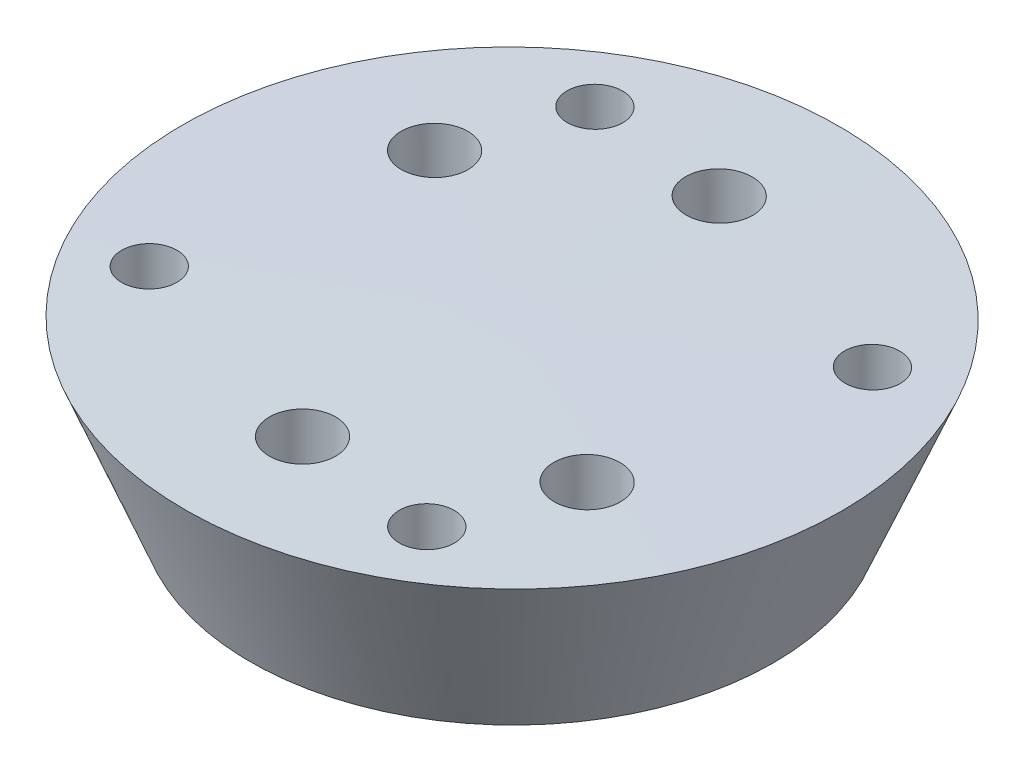
from build123d import *

# Parameters (mm, degrees)
SCHIZZO2_R                    = 2.5
TAGLIO_ESTRUSIONE1_DEPTH      = 21
TAGLIO_ESTRUSIONE1_DEPTH_BACK = 10
TAGLIO_ESTRUSIONE2_DEPTH      = 11
SCHIZZO4_R                    = 4
TAGLIO_ESTRUSIONE3_DEPTH      = 91


with BuildPart() as part:
    # Schizzo1 → Rivoluzione1 (revolve)
    with BuildSketch(Plane.XY):
        Polygon((0, -101.5), (0.147426206, -81.5), (-39.399917748, -81.5), (-31.5, -101.5), align=None)
    revolve(axis=Axis((0, -101.5, 0), (0.00737111, 0.999972833, 0)))

    # Schizzo2 → Taglio-Estrusione1 (cut, two sides)
    with BuildSketch(Plane(origin=(0, -101.5, 0), x_dir=(1, 0, 0), z_dir=(0, 1, 0))) as taglio_estrusione1_sk:
        with Locations((21.650635095, -12.5)):
            Circle(SCHIZZO2_R)
        with Locations((0, -25)):
            Circle(SCHIZZO2_R)
        with Locations((-21.650635095, 12.5)):
            Circle(SCHIZZO2_R)
        with Locations((0, 25)):
            Circle(SCHIZZO2_R)
    extrude(amount=TAGLIO_ESTRUSIONE1_DEPTH, mode=Mode.SUBTRACT)
    extrude(taglio_estrusione1_sk.sketch, amount=-TAGLIO_ESTRUSIONE1_DEPTH_BACK, mode=Mode.SUBTRACT)

    # Schizzo3 → Taglio-Estrusione2 (cut)
    with BuildSketch(Plane.XZ.offset(81.5)):
        with BuildLine():
            ThreePointArc((17.404264159, 23.501763124), (19.888877198, 27.491500276), (15.899140045, 29.976113315))
            ThreePointArc((15.899140045, 29.976113315), (13.414527007, 25.986376162), (17.404264159, 23.501763124))
        make_face()
        with BuildLine():
            ThreePointArc((29.976113315, -15.899140045), (25.986376162, -13.414527007), (23.501763124, -17.404264159))
            ThreePointArc((23.501763124, -17.404264159), (27.491500276, -19.888877198), (29.976113315, -15.899140045))
        make_face()
        with BuildLine():
            ThreePointArc((-15.899140045, -29.976113315), (-13.414527007, -25.986376162), (-17.404264159, -23.501763124))
            ThreePointArc((-17.404264159, -23.501763124), (-19.888877198, -27.491500276), (-15.899140045, -29.976113315))
        make_face()
        with BuildLine():
            ThreePointArc((-29.976113315, 15.899140045), (-25.986376162, 13.414527007), (-23.501763124, 17.404264159))
            ThreePointArc((-23.501763124, 17.404264159), (-27.491500276, 19.888877198), (-29.976113315, 15.899140045))
        make_face()
    extrude(amount=TAGLIO_ESTRUSIONE2_DEPTH, mode=Mode.SUBTRACT)

    # Schizzo4 → Taglio-Estrusione3 (cut)
    with BuildSketch(Plane(origin=(0, 0, 0), x_dir=(1, 0, 0), z_dir=(0, 1, 0))):
        with Locations((-21.650635095, 12.5)):
            Circle(SCHIZZO4_R)
        with Locations((0, 25)):
            Circle(SCHIZZO4_R)
        with Locations((21.650635095, -12.5)):
            Circle(SCHIZZO4_R)
        with Locations((0, -25)):
            Circle(SCHIZZO4_R)
    extrude(amount=-TAGLIO_ESTRUSIONE3_DEPTH, mode=Mode.SUBTRACT)


solid = part.part
